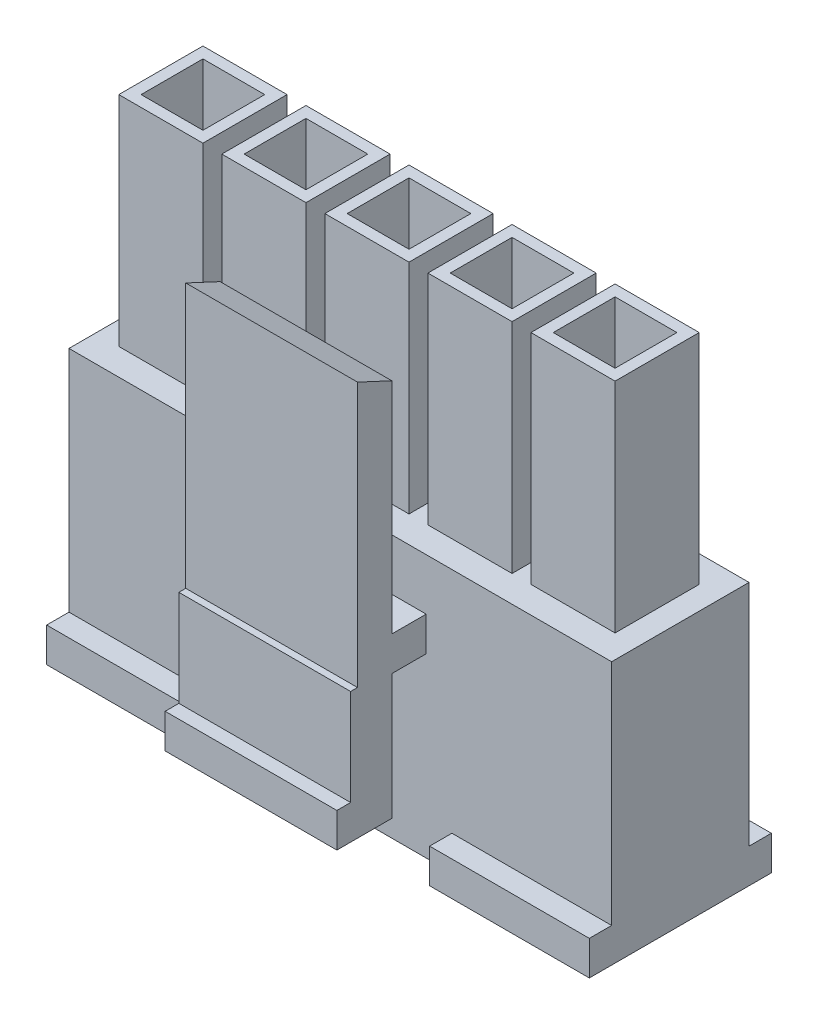
from build123d import *

# Parameters (mm, degrees)
SKETCH1_W           = 15.8
SKETCH1_H           = 4
SKETCH1_W_2         = 2.7
SKETCH1_H_2         = 2.7
BOSS_EXTRUDE1_DEPTH = 7.65
SKETCH2_W           = 15.8
SKETCH2_H           = 4
SKETCH2_W_2         = 1.8
SKETCH2_H_2         = 1.8
BOSS_EXTRUDE2_DEPTH = 1
SKETCH3_W           = 2.45
SKETCH3_H           = 2.45
SKETCH3_W_2         = 1.8
SKETCH3_H_2         = 1.8
BOSS_EXTRUDE3_DEPTH = 6.35
SKETCH4_W           = 4.65
SKETCH4_H           = 0.65
SKETCH4_W_2         = 15.8
BOSS_EXTRUDE4_DEPTH = 1
SKETCH5_W           = 1
SKETCH5_H           = 1
SKETCH5_W_2         = 0.4
BOSS_EXTRUDE5_DEPTH = 2.5


with BuildPart() as part:
    # Sketch1 → Boss-Extrude1 (new body)
    with BuildSketch(Plane(origin=(0, 0, 0), x_dir=(1, 0, 0), z_dir=(0, 1, 0))):
        Rectangle(SKETCH1_W, SKETCH1_H)
        Rectangle(SKETCH1_W_2, SKETCH1_H_2, mode=Mode.SUBTRACT)
        with Locations((3, 0)):
            Rectangle(SKETCH1_W_2, SKETCH1_H_2, mode=Mode.SUBTRACT)
        with Locations((6, 0)):
            Rectangle(SKETCH1_W_2, SKETCH1_H_2, mode=Mode.SUBTRACT)
        with Locations((-6, 0)):
            Rectangle(SKETCH1_W_2, SKETCH1_H_2, mode=Mode.SUBTRACT)
        with Locations((-3, 0)):
            Rectangle(SKETCH1_W_2, SKETCH1_H_2, mode=Mode.SUBTRACT)
    extrude(amount=BOSS_EXTRUDE1_DEPTH)

    # Sketch2 → Boss-Extrude2 (add)
    with BuildSketch(Plane(origin=(0, 7.65, 0), x_dir=(1, 0, 0), z_dir=(0, 1, 0))):
        Rectangle(SKETCH2_W, SKETCH2_H)
        with Locations((-6, 0)):
            Rectangle(SKETCH2_W_2, SKETCH2_H_2, mode=Mode.SUBTRACT)
        with Locations((-3, 0)):
            Rectangle(SKETCH2_W_2, SKETCH2_H_2, mode=Mode.SUBTRACT)
        Rectangle(SKETCH2_W_2, SKETCH2_H_2, mode=Mode.SUBTRACT)
        with Locations((3, 0)):
            Rectangle(SKETCH2_W_2, SKETCH2_H_2, mode=Mode.SUBTRACT)
        with Locations((6, 0)):
            Rectangle(SKETCH2_W_2, SKETCH2_H_2, mode=Mode.SUBTRACT)
    extrude(amount=-BOSS_EXTRUDE2_DEPTH)

    # Sketch3 → Boss-Extrude3 (add)
    with BuildSketch(Plane(origin=(0, 7.65, 0), x_dir=(1, 0, 0), z_dir=(0, 1, 0))):
        with Locations((-6, 0)):
            Rectangle(SKETCH3_W, SKETCH3_H)
        with Locations((-6, 0)):
            Rectangle(SKETCH3_W_2, SKETCH3_H_2, mode=Mode.SUBTRACT)
        with Locations((-3, 0)):
            Rectangle(SKETCH3_W, SKETCH3_H)
        with Locations((-3, 0)):
            Rectangle(SKETCH3_W_2, SKETCH3_H_2, mode=Mode.SUBTRACT)
        Rectangle(SKETCH3_W, SKETCH3_H)
        Rectangle(SKETCH3_W_2, SKETCH3_H_2, mode=Mode.SUBTRACT)
        with Locations((3, 0)):
            Rectangle(SKETCH3_W, SKETCH3_H)
        with Locations((3, 0)):
            Rectangle(SKETCH3_W_2, SKETCH3_H_2, mode=Mode.SUBTRACT)
        with Locations((6, 0)):
            Rectangle(SKETCH3_W, SKETCH3_H)
        with Locations((6, 0)):
            Rectangle(SKETCH3_W_2, SKETCH3_H_2, mode=Mode.SUBTRACT)
    extrude(amount=BOSS_EXTRUDE3_DEPTH)

    # Sketch4 → Boss-Extrude4 (add)
    with BuildSketch(Plane.XZ):
        with Locations((-5.575, 2.325)):
            Rectangle(SKETCH4_W, SKETCH4_H)
        with Locations((5.575, 2.325)):
            Rectangle(SKETCH4_W, SKETCH4_H)
        with Locations((0, -2.325)):
            Rectangle(SKETCH4_W_2, SKETCH4_H)
    extrude(amount=-BOSS_EXTRUDE4_DEPTH)

    # Sketch5 → Boss-Extrude5 (add, symmetric)
    with BuildSketch(Plane(origin=(0, 0, 0), x_dir=(0, 0, -1), z_dir=(1, 0, 0))):
        Polygon((-3, 5.15), (-3, 6.15), (-3, 12.533692342), (-4, 13), (-4, 5.3), (-4, 1.5), (-3, 1.5), align=None)
        with Locations((-2.5, 5.65)):
            Rectangle(SKETCH5_W, SKETCH5_H)
        Polygon((-4.2, 1.5), (-4, 1.5), (-4, 5.3), (-4.2, 5.3), (-4.2, 2.5), align=None)
        with Locations((-4.4, 2)):
            Rectangle(SKETCH5_W_2, SKETCH5_H)
    extrude(amount=BOSS_EXTRUDE5_DEPTH, both=True)


solid = part.part
